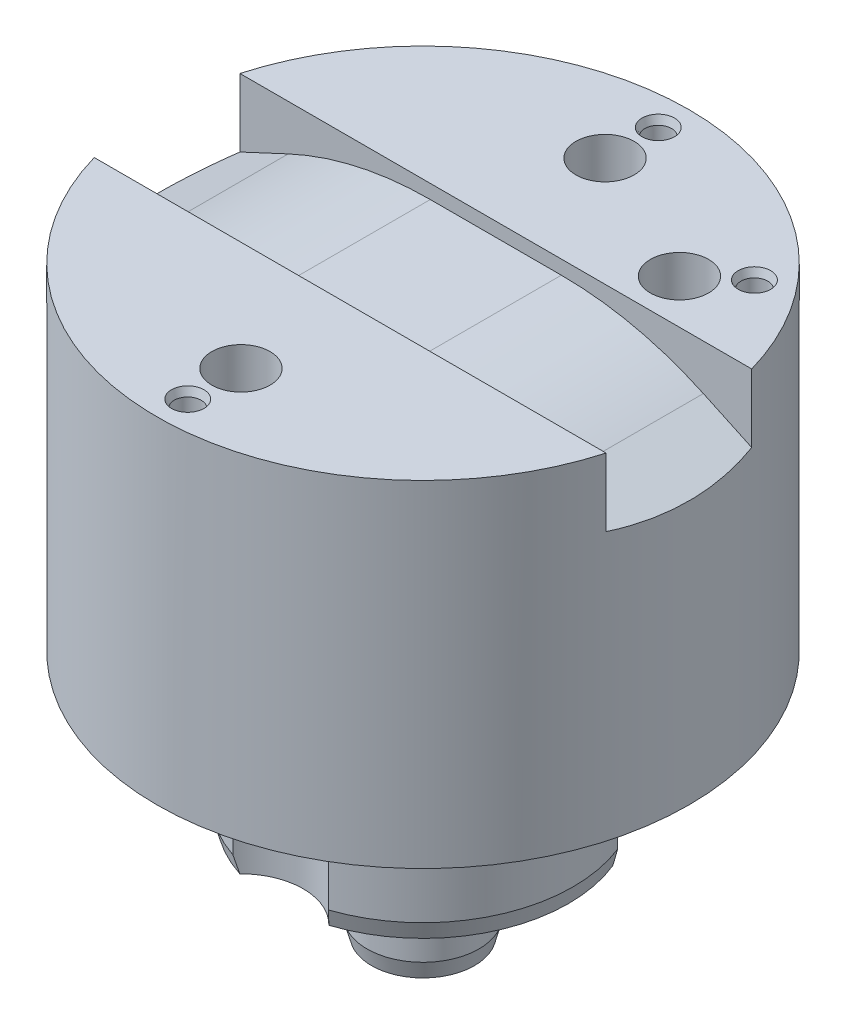
from build123d import *

# Parameters (mm, degrees)
CHAMFER2_SIZE                  = 0.4
CHAMFER2_SIZE2                 = 1.492820323
CHAMFER2_PART_2_SIZE           = 0.4
CHAMFER2_PART_2_SIZE2          = 1.492820323
CBORE_FOR_M5_SBHCS1_AT_2_COUNT = 2
CBORE_FOR_M5_SBHCS1_AT_2_PITCH = 32.5
CBORE_FOR_M5_SBHCS1_AT_3_COUNT = 2
CBORE_FOR_M5_SBHCS1_AT_3_PITCH = 29.455003079
SKETCH16_R                     = 5.55
CUT_EXTRUDE6_DEPTH             = 23
F_2_4_2_4_DIAMETER_HOLE1_D     = 2.4
F_2_4_2_4_DIAMETER_HOLE1_DEPTH = 2
CHAMFER1_SIZE                  = 0.25
CHAMFER1_SIZE2                 = 0.686869355
CUT_EXTRUDE8_DEPTH             = 6.5
FILLET1_R                      = 30


with BuildPart() as part:
    # Sketch1 → Revolve1 (revolve)
    with BuildSketch(Plane.XY):
        Polygon((5, -22), (5, -13), (13.4, -13), (13.4, 0), (23.75, 0), (23.75, 30), (0, 30), (0, -22), align=None)
    revolve(axis=Axis((0, 0, 0), (0, 1, 0)))

    # Chamfer2
    chamfer2_edges = [part.edges().sort_by_distance(p)[0] for p in [
        (-5, -22, 0),
    ]]
    chamfer2_side = [part.faces().sort_by_distance(p)[0] for p in [
        (0, -22, 0),
    ]]
    chamfer(chamfer2_edges, length=CHAMFER2_SIZE, length2=CHAMFER2_SIZE2, reference=chamfer2_side[0])

    # Chamfer2 part 2
    chamfer2_part_2_edges = [part.edges().sort_by_distance(p)[0] for p in [
        (-13.4, -13, 0),
    ]]
    chamfer2_part_2_side = [part.faces().sort_by_distance(p)[0] for p in [
        (-5.379009235, -13, 0),
    ]]
    chamfer(chamfer2_part_2_edges, length=CHAMFER2_PART_2_SIZE, length2=CHAMFER2_PART_2_SIZE2, reference=chamfer2_part_2_side[0])

    # Sketch15 → CBORE for M5 SBHCS1 (revolve, cut)
    with BuildSketch(Plane(origin=(0, 0, 16.25), x_dir=(0, 0, -1), z_dir=(1, 0, 0))):
        Polygon((0, 0), (0, 30), (2.6, 30), (2.6, 24), (5.55, 24), (5.55, 0), align=None)
    cbore_for_m5_sbhcs1 = revolve(axis=Axis((0, -6.35, 16.25), (0, 1, 0)), mode=Mode.SUBTRACT)

    # CBORE for M5 SBHCS1 at 2: CBORE for M5 SBHCS1 ×2
    with Locations(*[(0, 0, -i * CBORE_FOR_M5_SBHCS1_AT_2_PITCH) for i in range(1, CBORE_FOR_M5_SBHCS1_AT_2_COUNT)]):
        add(cbore_for_m5_sbhcs1, mode=Mode.SUBTRACT)

    # CBORE for M5 SBHCS1 at 3: CBORE for M5 SBHCS1 ×2
    with Locations(*[Vector(0.422618262, 0, -0.906307787) * (i * CBORE_FOR_M5_SBHCS1_AT_3_PITCH) for i in range(1, CBORE_FOR_M5_SBHCS1_AT_3_COUNT)]):
        add(cbore_for_m5_sbhcs1, mode=Mode.SUBTRACT)

    # Sketch16 → Cut-Extrude6 (cut, through all)
    with BuildSketch(Plane.XZ):
        with Locations((0, -16.25)):
            Circle(SKETCH16_R)
        with Locations((12.448222201, -10.445298657)):
            Circle(SKETCH16_R)
        with Locations((0, 16.25)):
            Circle(SKETCH16_R)
    extrude(amount=CUT_EXTRUDE6_DEPTH, mode=Mode.SUBTRACT)

    # Ø2.4 (2.4) Diameter Hole1
    with Locations(Plane(origin=(0, 30, 0), x_dir=(1, 0, 0), z_dir=(0, 1, 0))):
        with Locations((0, 21), (16.086933305, 13.498539803), (0, -21)):
            Hole(F_2_4_2_4_DIAMETER_HOLE1_D / 2, depth=F_2_4_2_4_DIAMETER_HOLE1_DEPTH)

    # Chamfer1
    chamfer1_edges = [part.edges().sort_by_distance(p)[0] for p in [
        (1.2, 30, 21),
        (17.286933305, 30, -13.498539803),
        (1.2, 30, -21),
    ]]
    chamfer1_side = [part.faces().sort_by_distance(p)[0] for p in [
        (-0.198929798, 30, 0.16692192),
    ]]
    chamfer(chamfer1_edges, length=CHAMFER1_SIZE, length2=CHAMFER1_SIZE2, reference=chamfer1_side[0])

    # Sketch30 → Cut-Extrude8 (cut, symmetric)
    with BuildSketch(Plane.XY):
        Polygon((-23.75, 30), (23.75, 30), (23.75, 23.504038846), (12.5, 28.75), (-12.5, 28.75), (-23.75, 23.504038846), align=None)
    extrude(amount=CUT_EXTRUDE8_DEPTH, both=True, mode=Mode.SUBTRACT)

    # Fillet1
    fillet1_edges = [part.edges().sort_by_distance(p)[0] for p in [
        (12.5, 28.75, 0),
        (-12.5, 28.75, 0),
    ]]
    fillet(fillet1_edges, radius=FILLET1_R)


solid = part.part
